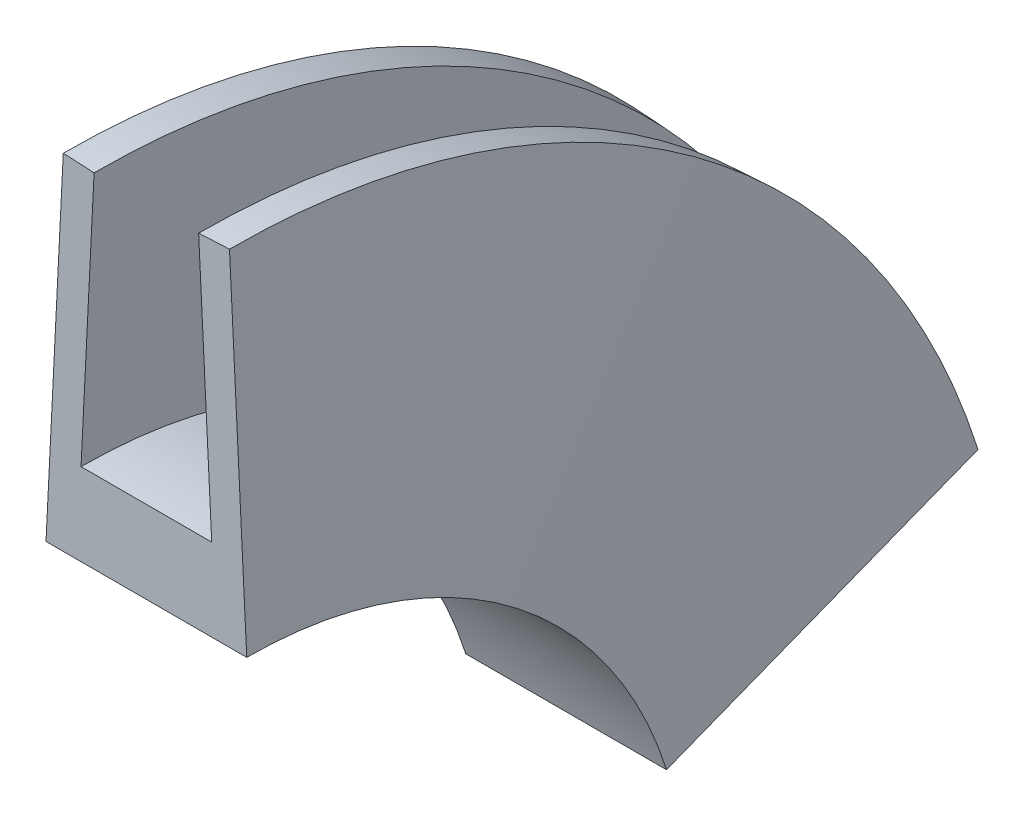
from build123d import *


with BuildPart() as part:
    # Sweep1: sweep along a path in Sketch3
    with BuildLine(Plane(origin=(0, 0, 0), x_dir=(0, 0, -1), z_dir=(1, 0, 0))) as sweep1_path:
        ThreePointArc((0, 0), (7.5, -2.45109762), (12.105002811, -8.858267717))
    # Sketch1 → Sweep1 (sweep)
    with BuildSketch(Plane.XY):
        Polygon((-2.019073099, 6.379558093), (-2.43857571, -2), (2.43857571, -2), (2.019073099, 6.379558093), (1.27, 6.342057533), (1.5875, 0), (-1.5875, 0), (-1.27, 6.342057533), align=None)
    sweep(path=sweep1_path.line)


solid = part.part
